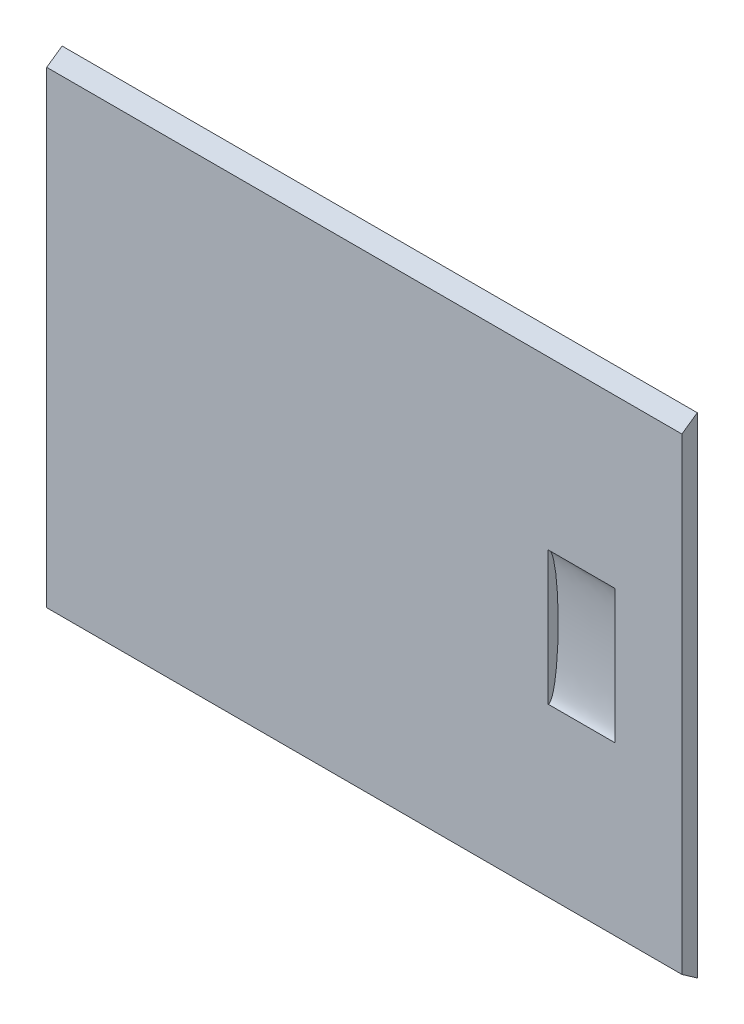
from build123d import *

# Parameters (mm, degrees)
ESBO_O1_W                = 4.6
ESBO_O1_H                = 140
RESSALTO_EXTRUS_O1_DEPTH = 190
CORTE_EXTRUS_O1_START    = -20
ESBO_O2_RX               = 20.00007904
ESBO_O2_RY               = 3.000011856
CORTE_EXTRUS_O1_DEPTH    = 20


with BuildPart() as part:
    # Esboço1 → Ressalto-extrusão1 (new body)
    with BuildSketch(Plane(origin=(0, 0, 0), x_dir=(0, 0, -1), z_dir=(1, 0, 0))):
        Rectangle(ESBO_O1_W, ESBO_O1_H)
        Polygon((2.3, 70), (-2.3, 70), (2.3, 73.220954676), align=None)
        Polygon((2.3, -70), (-2.3, -70), (2.3, -73.220954676), align=None)
    extrude(amount=RESSALTO_EXTRUS_O1_DEPTH)

    # Esboço2 → Corte-extrusão1 (cut)
    with BuildSketch(Plane(origin=(190, 0, 0), x_dir=(0, 0, -1), z_dir=(1, 0, 0)).offset(CORTE_EXTRUS_O1_START)):
        with Locations(Location((-2.3, 0), (0, 0, -89.838918547))):
            Ellipse(ESBO_O2_RX, ESBO_O2_RY)
    extrude(amount=-CORTE_EXTRUS_O1_DEPTH, mode=Mode.SUBTRACT)


solid = part.part
